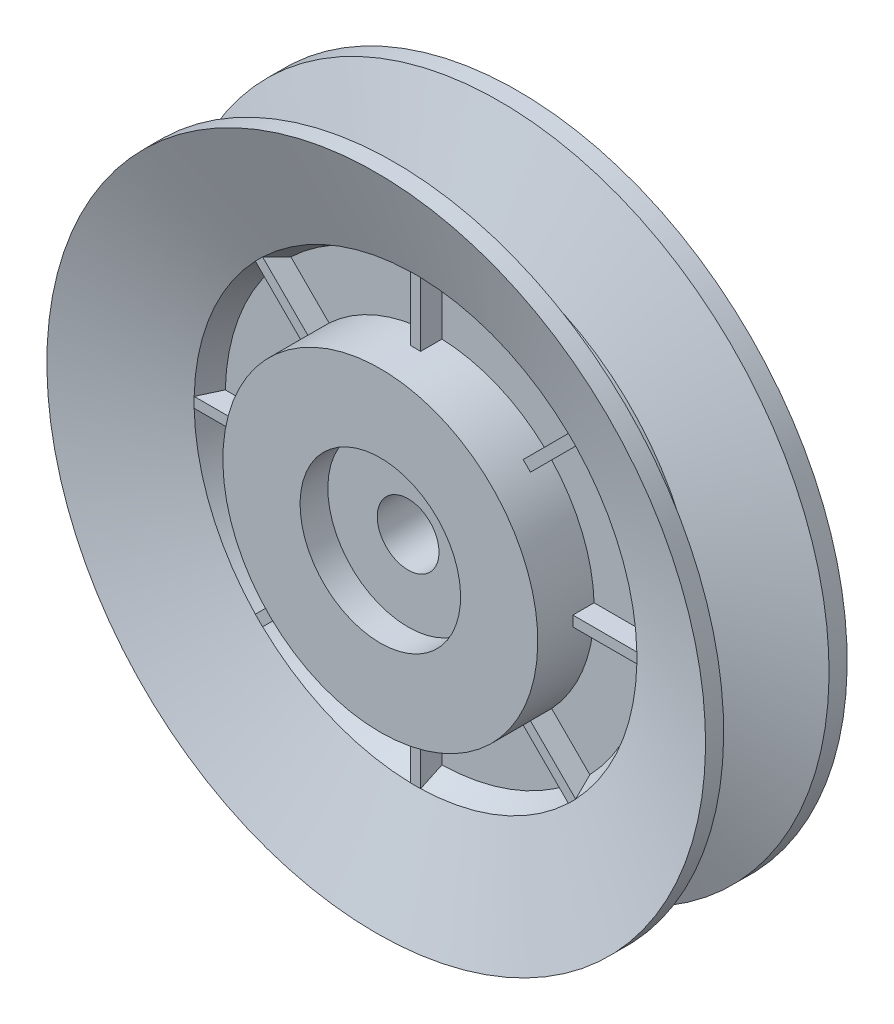
from build123d import *

# Parameters (mm, degrees)
SKETCH2_W           = 12
SKETCH2_H           = 15.2375
BOSS_EXTRUDE2_DEPTH = 0.79375
CIRPATTERN1_COUNT   = 8


with BuildPart() as part:
    # Sketch1 → Revolve1 (revolve)
    with BuildSketch(Plane(origin=(0, 0, 0), x_dir=(0, 0, -1), z_dir=(1, 0, 0))):
        Polygon((18.415, 50.8), (21.209, 50.8), (15.148201466, 34.148092884), (11.8745, 32.62154082), (11.8745, 24.287), (20.574, 24.287), (20.574, 12.38125), (16.287, 12.38125), (16.287, 20), (4.287, 20), (4.287, 12.38125), (0, 12.38125), (0, 24.287), (8.6995, 24.287), (8.6995, 32.62154082), (5.425798534, 34.148092884), (-0.635, 50.8), (2.159, 50.8), (7.521009491, 36.068), (13.052990509, 36.068), align=None)
    revolve(axis=Axis((0, 0, 0), (0, 0, -1)))

    # Sketch4 → Boss-Extrude2 (add, symmetric)
    with BuildSketch(Plane(origin=(0, 0, 0), x_dir=(0, 0, -1), z_dir=(1, 0, 0))):
        Polygon((8.6995, 32.62154082), (8.6995, 24.287), (8.6995, 23.017), (5.425798534, 23.017), (5.425798534, 24.287), (5.425798534, 34.148092884), align=None)
        Polygon((15.148201466, 23.017), (15.148201466, 24.287), (15.148201466, 34.148092884), (11.8745, 32.62154082), (11.8745, 24.287), (11.8745, 23.017), align=None)
    boss_extrude2 = extrude(amount=BOSS_EXTRUDE2_DEPTH, both=True)

    # CirPattern1: Boss-Extrude2 ×8 about axis
    cirpattern1_axis = Axis((0, 0, 0), (0, 0, 1))
    for i in range(1, CIRPATTERN1_COUNT):
        add(boss_extrude2.rotate(cirpattern1_axis, i * 360 / CIRPATTERN1_COUNT))


with BuildPart() as body_2:
    # Sketch2 → Revolve2 (revolve)
    with BuildSketch(Plane(origin=(0, 0, 0), x_dir=(0, 0, -1), z_dir=(1, 0, 0))):
        with Locations((10.287, 12.38125)):
            Rectangle(SKETCH2_W, SKETCH2_H)
    revolve(axis=Axis((0, 0, 0), (0, 0, -1)))


solid = Compound([part.part, body_2.part])
